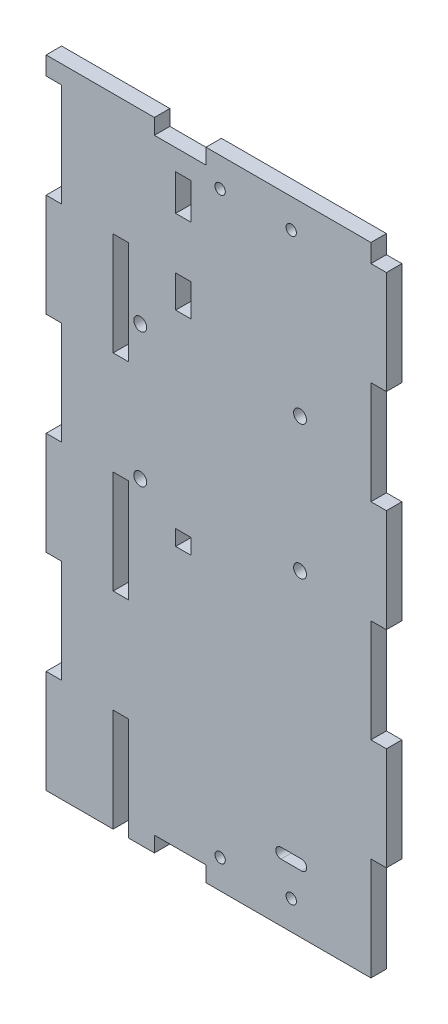
from build123d import *

# Parameters (mm, degrees)
ESQUISSE1_R        = 2.500000039
ESQUISSE1_R_2      = 2.5
ESQUISSE1_R_3      = 2.50000052
ESQUISSE1_R_4      = 2.500000067
ESQUISSE1_R_5      = 2
ESQUISSE1_W        = 6
ESQUISSE1_H        = 40
ESQUISSE1_H_2      = 14.000000003
ESQUISSE1_H_3      = 12.5
ESQUISSE1_H_4      = 6
BOSS_EXTRU_1_DEPTH = 6


with BuildPart() as part:
    # Esquisse1 → Boss.-Extru.1 (new body)
    with BuildSketch(Plane.XY):
        Polygon((-395.568859933, 174.308023863), (-401.568859933, 174.308023863), (-401.568859933, 181.409908735), (-465.568859933, 181.409908735), (-465.568859933, 175.409908735), (-485.568859933, 175.409908735), (-485.568859933, 181.409908735), (-501.568859933, 181.409908735), (-527.568859933, 181.409908735), (-527.568859933, 174.308023863), (-521.568859933, 174.308023863), (-521.568859933, 134.309238722), (-527.568859933, 134.309238722), (-527.568859933, 94.307416433), (-521.568859933, 94.307416433), (-521.568859933, 54.308631292), (-527.568859933, 54.308631292), (-527.568859933, 14.306809003), (-521.568859933, 14.306809003), (-521.568859933, -25.691976137), (-527.568859933, -25.691976137), (-527.568859933, -65.693190997), (-501.568859933, -65.693190997), (-501.568859933, -25.693190997), (-495.568859933, -25.693190997), (-495.568859933, -65.693190997), (-485.568859933, -65.693190997), (-485.568859933, -59.693190997), (-465.568859933, -59.693190997), (-465.568859933, -65.693190997), (-401.568859933, -65.693190997), (-401.568859933, -25.691976137), (-395.568859933, -25.691976137), (-395.568859933, 14.306809003), (-401.568859933, 14.306809003), (-401.568859933, 54.308631292), (-395.568859933, 54.308631292), (-395.568859933, 94.307416433), (-401.568859933, 94.307416433), (-401.568859933, 134.309238722), (-395.568859933, 134.309238722), align=None)
        with Locations((-491.068859894, 57.306809003)):
            Circle(ESQUISSE1_R, mode=Mode.SUBTRACT)
        with Locations((-491.068859933, 109.306809003)):
            Circle(ESQUISSE1_R_2, mode=Mode.SUBTRACT)
        with Locations((-429.068859933, 109.306809003)):
            Circle(ESQUISSE1_R_3, mode=Mode.SUBTRACT)
        with Locations((-429.068859933, 57.306809003)):
            Circle(ESQUISSE1_R_4, mode=Mode.SUBTRACT)
        with Locations((-460.068859933, 170.159908735)):
            Circle(ESQUISSE1_R_5, mode=Mode.SUBTRACT)
        with Locations((-432.48625686, 170.159908735)):
            Circle(ESQUISSE1_R_5, mode=Mode.SUBTRACT)
        with Locations((-460.068859933, -54.443190997)):
            Circle(ESQUISSE1_R_5, mode=Mode.SUBTRACT)
        with Locations((-432.48625686, -54.443190997)):
            Circle(ESQUISSE1_R_5, mode=Mode.SUBTRACT)
        with BuildLine():
            Line((-428.48625686, -39.193190997), (-436.48625686, -39.193190997))
            ThreePointArc((-436.48625686, -39.193190997), (-438.48625686, -41.193190997), (-436.48625686, -43.193190997))
            Line((-436.48625686, -43.193190997), (-428.48625686, -43.193190997))
            ThreePointArc((-428.48625686, -43.193190997), (-426.48625686, -41.193190997), (-428.48625686, -39.193190997))
        make_face(mode=Mode.SUBTRACT)
        with Locations((-498.568859933, 34.306809003)):
            Rectangle(ESQUISSE1_W, ESQUISSE1_H, mode=Mode.SUBTRACT)
        with Locations((-498.568859933, 114.306809003)):
            Rectangle(ESQUISSE1_W, ESQUISSE1_H, mode=Mode.SUBTRACT)
        with Locations((-474.318859933, 160.306809004)):
            Rectangle(ESQUISSE1_W, ESQUISSE1_H_2, mode=Mode.SUBTRACT)
        with Locations((-474.318859933, 127.056809003)):
            Rectangle(ESQUISSE1_W, ESQUISSE1_H_3, mode=Mode.SUBTRACT)
        with Locations((-474.318859933, 44.409908732)):
            Rectangle(ESQUISSE1_W, ESQUISSE1_H_4, mode=Mode.SUBTRACT)
    extrude(amount=-BOSS_EXTRU_1_DEPTH)


solid = part.part
